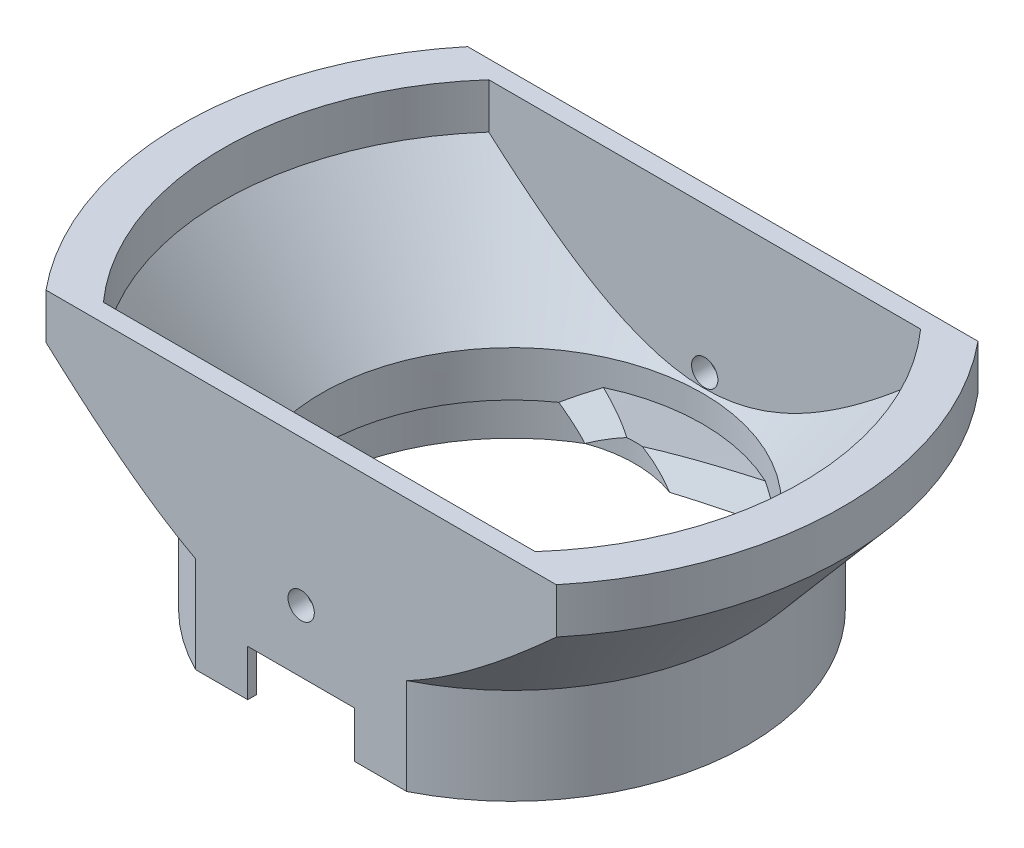
from build123d import *

# Parameters (mm, degrees)
SKETCH2_W           = 56.273883818
SKETCH2_H           = 13.25
CUT_EXTRUDE1_DEPTH  = 58.797058749
BOSS_EXTRUDE2_REACH = 52.486
SKETCH6_W           = 56.273883818
SKETCH6_H           = 2
SKETCH3_W           = 11.78
SKETCH3_H           = 0.962657039
CUT_EXTRUDE2_DEPTH  = 3.1
SKETCH7_R           = 1.45
CUT_EXTRUDE3_DEPTH  = 65.579408483
REVOLVE2_ANGLE      = 70
BOSS_EXTRUDE5_DEPTH = 2
SKETCH16_R          = 13.55
CUT_EXTRUDE6_DEPTH  = 49.961438909
DRAFT11_ANGLE       = -60


with BuildPart() as part:
    # Sketch1 → Revolve1 (revolve)
    with BuildSketch(Plane(origin=(0, 0, 0), x_dir=(0, 0, -1), z_dir=(1, 0, 0)), mode=Mode.PRIVATE) as revolve1_sk:
        Polygon((-26, 0), (-26, 8.590696852), (-36.5, 21), (-36.5, 26), (-31.915197927, 26), (-31.915197927, 21), (-21, 8.1), (-21, 3.1), (-23.0525, 3.1), (-23.0525, 0), align=None)
    revolve(revolve1_sk.sketch.rotate(Axis((0, 0, 0), (0, 1, 0)), 180), axis=Axis((0, 0, 0), (0, 1, 0)))

    # Sketch2 → Cut-Extrude1 (cut, through all)
    with BuildSketch(Plane.XZ):
        with Locations((0, -29.875)):
            Rectangle(SKETCH2_W, SKETCH2_H)
        with Locations((0, 29.875)):
            Rectangle(SKETCH2_W, SKETCH2_H)
    extrude(amount=-CUT_EXTRUDE1_DEPTH, mode=Mode.SUBTRACT)

    # Boss-Extrude2: up to this cone (the profile starts inside it)
    boss_extrude2_end = Plane(origin=(0, 26, 0), z_dir=(0, 1, 0)).offset(-42.718605296) * Cone(1e-06, 111.563900484, 131.850500094, align=(Align.CENTER, Align.CENTER, Align.MIN), mode=Mode.PRIVATE)
    # Sketch6 → Boss-Extrude2 (add, up to the surface)
    with BuildSketch(Plane(origin=(0, 26, 0), x_dir=(1, 0, 0), z_dir=(0, 1, 0)), mode=Mode.PRIVATE) as boss_extrude2_sk1:
        with Locations((0, 22.25)):
            Rectangle(SKETCH6_W, SKETCH6_H)
    boss_extrude2_tool1 = extrude(boss_extrude2_sk1.sketch, amount=-BOSS_EXTRUDE2_REACH, mode=Mode.PRIVATE) & boss_extrude2_end
    add(boss_extrude2_tool1.solids().sort_by_distance((0, 26, -22.25))[0])
    # Sketch6 → Boss-Extrude2 (add, up to the surface)
    with BuildSketch(Plane(origin=(0, 26, 0), x_dir=(1, 0, 0), z_dir=(0, 1, 0)), mode=Mode.PRIVATE) as boss_extrude2_sk2:
        with Locations((0, -22.25)):
            Rectangle(SKETCH6_W, SKETCH6_H)
    boss_extrude2_tool2 = extrude(boss_extrude2_sk2.sketch, amount=-BOSS_EXTRUDE2_REACH, mode=Mode.PRIVATE) & boss_extrude2_end
    add(boss_extrude2_tool2.solids().sort_by_distance((0, 26, 22.25))[0])

    # Sketch3 → Cut-Extrude2 (cut)
    with BuildSketch(Plane.XZ):
        with Locations((0, -22.768671481)):
            Rectangle(SKETCH3_W, SKETCH3_H)
        with Locations((0, 22.768671481)):
            Rectangle(SKETCH3_W, SKETCH3_H)
    extrude(amount=-CUT_EXTRUDE2_DEPTH, mode=Mode.SUBTRACT)

    # Sketch7 → Cut-Extrude3 (cut, through all)
    with BuildSketch(Plane(origin=(0, 0, -23.25), x_dir=(-1, 0, 0), z_dir=(0, 0, -1))):
        with Locations(Location((0, 9.95, 0), (0, 0, 90))):
            Circle(SKETCH7_R)
    extrude(amount=-CUT_EXTRUDE3_DEPTH, mode=Mode.SUBTRACT)

    # Sketch9 → Revolve2 (revolve, symmetric)
    with BuildSketch(Plane(origin=(0, 0, 0), x_dir=(0, 0, -1), z_dir=(1, 0, 0))) as revolve2_sk:
        Polygon((21.518312402, 5.031670845), (21, 3.1), (10.375810352, 5.950718212), (10.894122754, 7.882389057), align=None)
    revolve2 = revolve(axis=Axis((0, 0, 0), (0, 1, 0)), revolution_arc=REVOLVE2_ANGLE / 2)
    revolve2 = revolve2 + revolve(revolve2_sk.sketch, axis=Axis((0, 0, 0), (0, -1, 0)), revolution_arc=REVOLVE2_ANGLE / 2)

    # Mirror3: Revolve2 across plane
    add(revolve2.mirror(Plane.XY))

    # Sketch13 → Boss-Extrude5 (add)
    with BuildSketch(Plane.XZ):
        with BuildLine():
            Line((-5.89, -23.25), (-5.89, -22.287342961))
            ThreePointArc((-5.89, -22.287342961), (-23.0525, 0), (-5.89, 22.287342961))
            Line((-5.89, 22.287342961), (-5.89, 23.25))
            Line((-5.89, 23.25), (-11.637761812, 23.25))
            ThreePointArc((-11.637761812, 23.25), (-26, 0), (-11.637761812, -23.25))
            Line((-11.637761812, -23.25), (-5.89, -23.25))
        make_face()
        with BuildLine():
            Line((5.89, -22.287342961), (5.89, -23.25))
            Line((5.89, -23.25), (11.637761812, -23.25))
            ThreePointArc((11.637761812, -23.25), (26, 0), (11.637761812, 23.25))
            Line((11.637761812, 23.25), (5.89, 23.25))
            Line((5.89, 23.25), (5.89, 22.287342961))
            ThreePointArc((5.89, 22.287342961), (23.0525, 0), (5.89, -22.287342961))
        make_face()
    extrude(amount=BOSS_EXTRUDE5_DEPTH)

    # Sketch16 → Cut-Extrude6 (cut, through all)
    with BuildSketch(Plane.XZ.offset(-3.1)):
        Circle(SKETCH16_R)
    extrude(amount=-CUT_EXTRUDE6_DEPTH, mode=Mode.SUBTRACT)

    # Draft11
    draft11_faces = [part.faces().sort_by_distance(p)[0] for p in [
        (9.908532938, 5.134877582, 14.150851565),
        (-9.908532938, 5.134877582, 14.150851565),
        (9.908532938, 5.134877582, -14.150851565),
        (-9.908532938, 5.134877582, -14.150851565),
    ]]
    draft(draft11_faces, Plane(origin=(0, 3.1, 0), x_dir=(0, 0, -1), z_dir=(0, -1, 0)), DRAFT11_ANGLE)


solid = part.part
